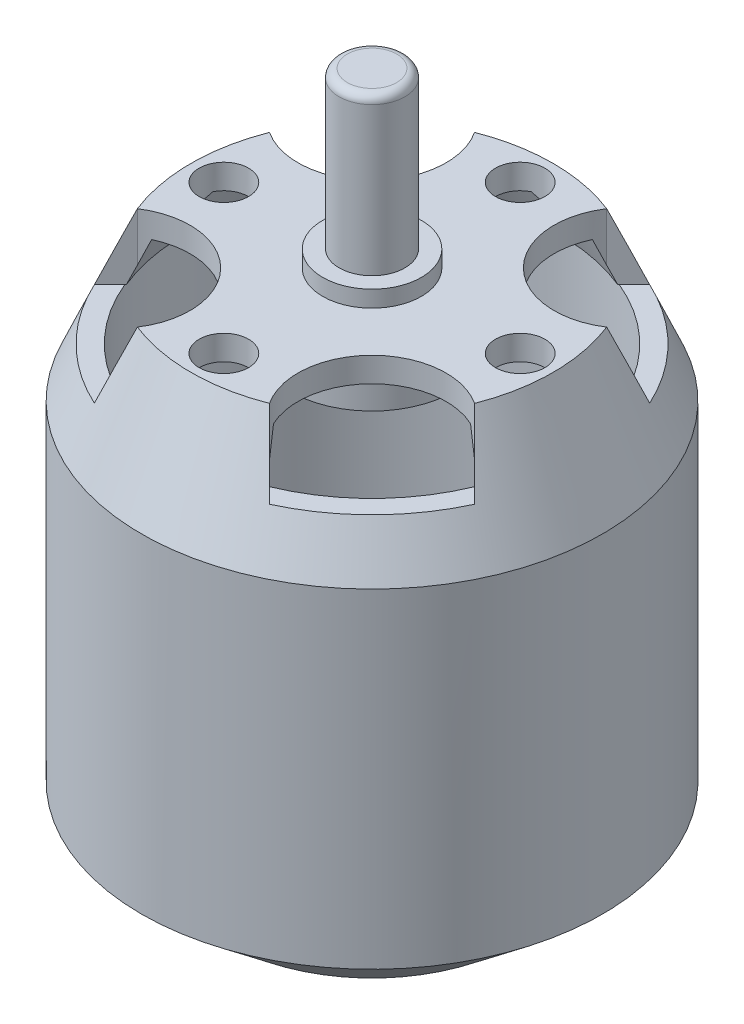
from build123d import *

# Parameters (mm, degrees)
SKETCH1_R           = 14
BOSS_EXTRUDE1_DEPTH = 18
SKETCH2_R           = 11
SKETCH3_R           = 3
SKETCH3_R_2         = 1.5
BOSS_EXTRUDE2_DEPTH = 1
SKETCH4_R           = 2
BOSS_EXTRUDE3_DEPTH = 10.5
SKETCH7_R           = 14
BOSS_EXTRUDE5_DEPTH = 2
SKETCH5_R           = 9
SKETCH6_R           = 4.5
BOSS_EXTRUDE4_DEPTH = 2
SKETCH9_R           = 1.5
CUT_EXTRUDE5_DEPTH  = 4
SKETCH10_R          = 1.5
CUT_EXTRUDE6_DEPTH  = 4
SKETCH11_R          = 1
CUT_EXTRUDE7_DEPTH  = 2
CUT_EXTRUDE8_DEPTH  = 4
SKETCH13_R          = 11.5
CUT_EXTRUDE9_DEPTH  = 22.5
FILLET1_R           = 0.5


with BuildPart() as part:
    # Sketch1 → Boss-Extrude1 (new body)
    with BuildSketch(Plane(origin=(0, 0, 0), x_dir=(1, 0, 0), z_dir=(0, 1, 0))):
        Circle(SKETCH1_R)
    extrude(amount=BOSS_EXTRUDE1_DEPTH)

    # Sketch2 → section 0 of loft1
    with BuildSketch(Plane(origin=(0, 25, 0), x_dir=(1, 0, 0), z_dir=(0, 1, 0)), mode=Mode.PRIVATE) as loft1_s0:
        Circle(SKETCH2_R)
    # loft up to a face of the part (loft1)
    loft([loft1_s0.sketch, part.faces().sort_by_distance((0, 18, 0))[0]])

    # Sketch3 → Boss-Extrude2 (add)
    with BuildSketch(Plane(origin=(0, 25, 0), x_dir=(1, 0, 0), z_dir=(0, 1, 0))):
        Circle(SKETCH3_R)
        Circle(SKETCH3_R_2, mode=Mode.SUBTRACT)
    extrude(amount=BOSS_EXTRUDE2_DEPTH)

    # Sketch4 → Boss-Extrude3 (add)
    with BuildSketch(Plane(origin=(0, 25, 0), x_dir=(1, 0, 0), z_dir=(0, 1, 0))):
        Circle(SKETCH4_R)
    extrude(amount=BOSS_EXTRUDE3_DEPTH)

    # Sketch7 → Boss-Extrude5 (add)
    with BuildSketch(Plane.XZ):
        Circle(SKETCH7_R)
    extrude(amount=BOSS_EXTRUDE5_DEPTH)

    # Sketch5 → section 0 of loft2
    with BuildSketch(Plane(origin=(0, -6, 0), x_dir=(-1, 0, 0), z_dir=(0, -1, 0)), mode=Mode.PRIVATE) as loft2_s0:
        Circle(SKETCH5_R)
    # loft up to a face of the part (loft2)
    loft([loft2_s0.sketch, part.faces().sort_by_distance((0, -2, 0))[0]])

    # Sketch6 → Boss-Extrude4 (add)
    with BuildSketch(Plane.XZ.offset(6)):
        Circle(SKETCH6_R)
    extrude(amount=BOSS_EXTRUDE4_DEPTH)

    # Sketch9 → Cut-Extrude5 (cut)
    with BuildSketch(Plane(origin=(0, 25, 0), x_dir=(1, 0, 0), z_dir=(0, 1, 0))):
        with Locations((0, 9)):
            Circle(SKETCH9_R)
        with Locations((9, 0)):
            Circle(SKETCH9_R)
        with Locations((0, -9)):
            Circle(SKETCH9_R)
        with Locations((-9, 0)):
            Circle(SKETCH9_R)
    extrude(amount=-CUT_EXTRUDE5_DEPTH, mode=Mode.SUBTRACT)

    # Sketch10 → Cut-Extrude6 (cut)
    with BuildSketch(Plane.XZ.offset(6)):
        with Locations((0, 9)):
            Circle(SKETCH10_R)
        with Locations((9, 0)):
            Circle(SKETCH10_R)
        with Locations((0, -9)):
            Circle(SKETCH10_R)
        with Locations((-9, 0)):
            Circle(SKETCH10_R)
    extrude(amount=-CUT_EXTRUDE6_DEPTH, mode=Mode.SUBTRACT)

    # Sketch11 → Cut-Extrude7 (cut)
    with BuildSketch(Plane.XZ.offset(6)):
        with Locations((0, 6)):
            Circle(SKETCH11_R)
        with Locations((6, 0)):
            Circle(SKETCH11_R)
        with Locations((0, -6)):
            Circle(SKETCH11_R)
        with Locations((-6, 0)):
            Circle(SKETCH11_R)
    extrude(amount=-CUT_EXTRUDE7_DEPTH, mode=Mode.SUBTRACT)

    # Sketch12 → Cut-Extrude8 (cut)
    with BuildSketch(Plane(origin=(0, 25, 0), x_dir=(1, 0, 0), z_dir=(0, 1, 0))):
        with BuildLine():
            Line((-10.242019056, -4.012610829), (-13.01419905, -6.784790823))
            Line((-13.01419905, -6.784790823), (-6.784790823, -13.01419905))
            Line((-6.784790823, -13.01419905), (-4.012610829, -10.242019056))
            ThreePointArc((-4.012610829, -10.242019056), (-4.596194078, -4.596194078), (-10.242019056, -4.012610829))
        make_face()
        with BuildLine():
            Line((-13.01419905, 6.784790823), (-10.242019056, 4.012610829))
            ThreePointArc((-10.242019056, 4.012610829), (-4.596194078, 4.596194078), (-4.012610829, 10.242019056))
            Line((-4.012610829, 10.242019056), (-6.784790823, 13.01419905))
            Line((-6.784790823, 13.01419905), (-13.01419905, 6.784790823))
        make_face()
        with BuildLine():
            Line((6.784790823, 13.01419905), (4.012610829, 10.242019056))
            ThreePointArc((4.012610829, 10.242019056), (4.596194078, 4.596194078), (10.242019056, 4.012610829))
            Line((10.242019056, 4.012610829), (13.01419905, 6.784790823))
            Line((13.01419905, 6.784790823), (6.784790823, 13.01419905))
        make_face()
        with BuildLine():
            Line((13.01419905, -6.784790823), (10.242019056, -4.012610829))
            ThreePointArc((10.242019056, -4.012610829), (4.596194078, -4.596194078), (4.012610829, -10.242019056))
            Line((4.012610829, -10.242019056), (6.784790823, -13.01419905))
            Line((6.784790823, -13.01419905), (13.01419905, -6.784790823))
        make_face()
    extrude(amount=-CUT_EXTRUDE8_DEPTH, mode=Mode.SUBTRACT)

    # Sketch13 → Cut-Extrude9 (cut)
    with BuildSketch(Plane(origin=(0, 21, 0), x_dir=(1, 0, 0), z_dir=(0, 1, 0))):
        Circle(SKETCH13_R)
    extrude(amount=-CUT_EXTRUDE9_DEPTH, mode=Mode.SUBTRACT)

    # Fillet1
    fillet1_edges = [part.edges().sort_by_distance(p)[0] for p in [
        (-2, 35.5, 0),
        (-4.5, -8, 0),
    ]]
    fillet(fillet1_edges, radius=FILLET1_R)

    # Sketch17 → Cut-Revolve1 (revolve, cut)
    with BuildSketch(Plane.XY):
        Polygon((-10.36813992, 23.5), (-11.439568492, 21), (-5, 21), (-5, 23.5), align=None)
    revolve(axis=Axis((0, 25, 0), (0, -1, 0)), mode=Mode.SUBTRACT)


solid = part.part
